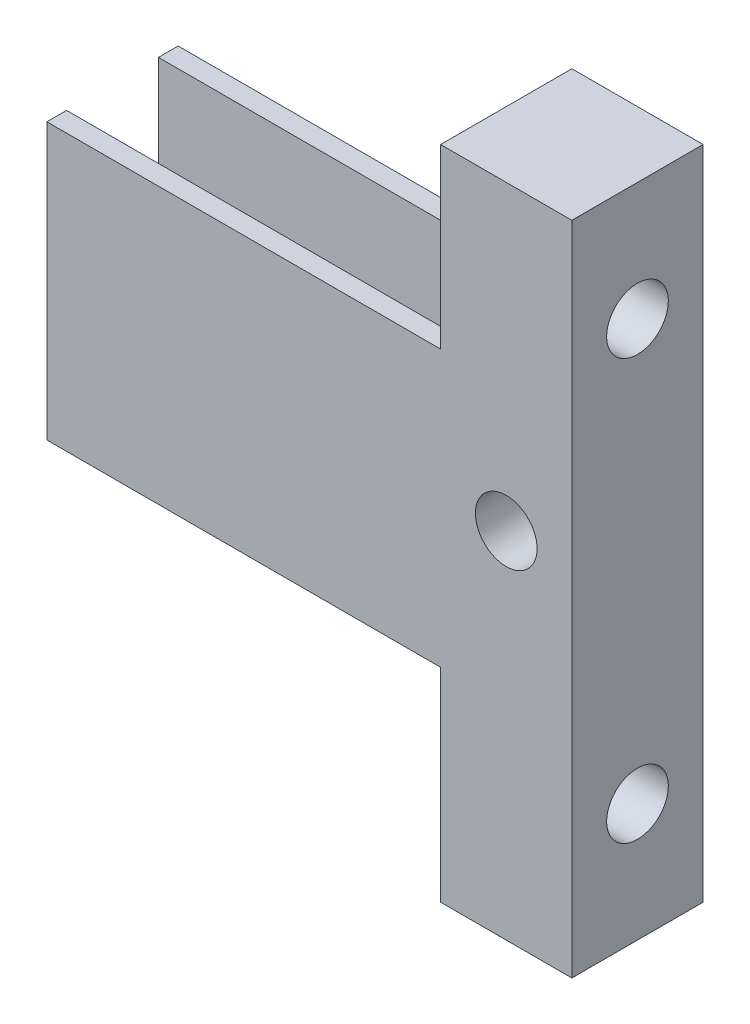
from build123d import *

# Parameters (mm, degrees)
SKETCH2_W           = 10
SKETCH2_H           = 50
BOSS_EXTRUDE1_DEPTH = 10
SKETCH6_R           = 2.35
CUT_EXTRUDE3_DEPTH  = 11
SKETCH7_R           = 2.35
CUT_EXTRUDE4_DEPTH  = 11
SKETCH8_W           = 1.5
SKETCH8_H           = 21
BOSS_EXTRUDE2_DEPTH = 30


with BuildPart() as part:
    # Sketch2 → Boss-Extrude1 (new body)
    with BuildSketch(Plane.XY):
        with Locations((5, 25)):
            Rectangle(SKETCH2_W, SKETCH2_H)
    extrude(amount=BOSS_EXTRUDE1_DEPTH)

    # Sketch6 → Cut-Extrude3 (cut, through all)
    with BuildSketch(Plane.XY.offset(10)):
        with Locations((5, 27)):
            Circle(SKETCH6_R)
    extrude(amount=-CUT_EXTRUDE3_DEPTH, mode=Mode.SUBTRACT)

    # Sketch7 → Cut-Extrude4 (cut, through all)
    with BuildSketch(Plane.ZY):
        with Locations((5, 41)):
            Circle(SKETCH7_R)
        with Locations((5, 9)):
            Circle(SKETCH7_R)
    extrude(amount=-CUT_EXTRUDE4_DEPTH, mode=Mode.SUBTRACT)

    # Sketch8 → Boss-Extrude2 (add)
    with BuildSketch(Plane.ZY):
        with Locations((9.25, 26)):
            Rectangle(SKETCH8_W, SKETCH8_H)
        with Locations((0.75, 26)):
            Rectangle(SKETCH8_W, SKETCH8_H)
    extrude(amount=BOSS_EXTRUDE2_DEPTH)


solid = part.part
